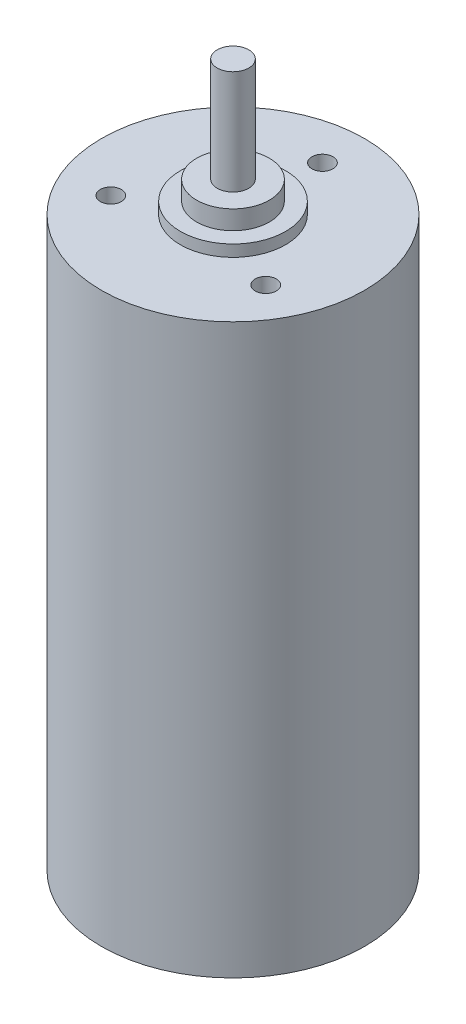
from build123d import *

# Parameters (mm, degrees)
SKETCH1_R                 = 12.5
BOSS_EXTRUDE1_DEPTH       = 54
SKETCH2_R                 = 5
BOSS_EXTRUDE2_DEPTH       = 1.1
SKETCH3_R                 = 3.455150035
BOSS_EXTRUDE3_DEPTH       = 1.8
SKETCH4_R                 = 1.5
BOSS_EXTRUDE4_DEPTH       = 9.9
F_2_0MM_DOWEL_HOLE1_D     = 2
F_2_0MM_DOWEL_HOLE1_DEPTH = 2.8999942
F_2_0MM_DOWEL_HOLE1_TIP   = 0.600860619


with BuildPart() as part:
    # Sketch1 → Boss-Extrude1 (new body)
    with BuildSketch(Plane(origin=(0, 0, 0), x_dir=(1, 0, 0), z_dir=(0, 1, 0))):
        Circle(SKETCH1_R)
    extrude(amount=BOSS_EXTRUDE1_DEPTH)

    # Sketch2 → Boss-Extrude2 (add)
    with BuildSketch(Plane(origin=(0, 54, 0), x_dir=(1, 0, 0), z_dir=(0, 1, 0))):
        Circle(SKETCH2_R)
    extrude(amount=BOSS_EXTRUDE2_DEPTH)

    # Sketch3 → Boss-Extrude3 (add)
    with BuildSketch(Plane(origin=(0, 55.1, 0), x_dir=(1, 0, 0), z_dir=(0, 1, 0))):
        Circle(SKETCH3_R)
    extrude(amount=BOSS_EXTRUDE3_DEPTH)

    # Sketch4 → Boss-Extrude4 (add)
    with BuildSketch(Plane(origin=(0, 56.9, 0), x_dir=(1, 0, 0), z_dir=(0, 1, 0))):
        Circle(SKETCH4_R)
    extrude(amount=BOSS_EXTRUDE4_DEPTH)

    # Ø2.0mm Dowel Hole1
    with Locations(Plane(origin=(0, 54, 0), x_dir=(1, 0, 0), z_dir=(0, 1, 0))):
        with Locations((-7.361215932, -4.25), (0, 8.5), (7.361215932, -4.25)):
            Hole(F_2_0MM_DOWEL_HOLE1_D / 2, depth=F_2_0MM_DOWEL_HOLE1_DEPTH)
            with Locations((0, 0, -(F_2_0MM_DOWEL_HOLE1_DEPTH + F_2_0MM_DOWEL_HOLE1_TIP / 2))):  # 118° drill point
                Cone(0, F_2_0MM_DOWEL_HOLE1_D / 2, F_2_0MM_DOWEL_HOLE1_TIP, mode=Mode.SUBTRACT)


solid = part.part
